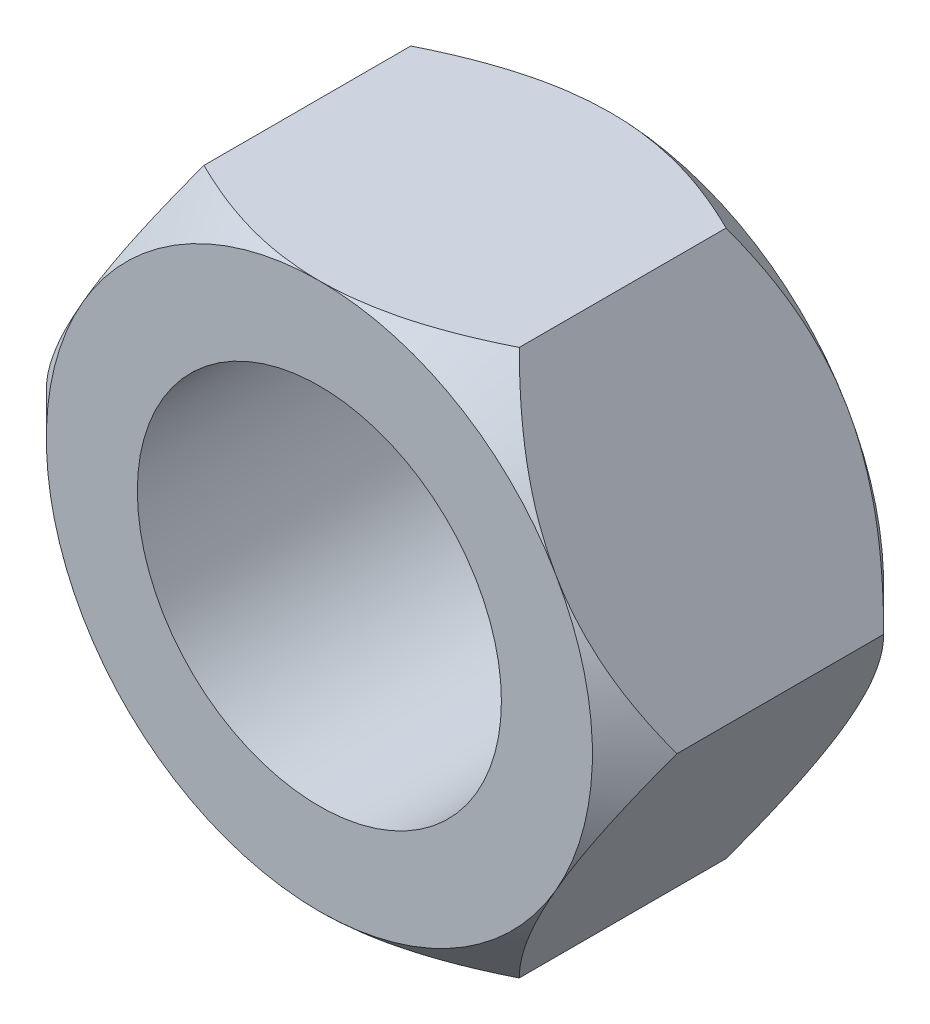
from build123d import *

# Parameters (mm, degrees)
BOSS_EXTRUDE1_DEPTH = 8
SKETCH2_OUTSIDE_W   = 80.35
SKETCH2_OUTSIDE_H   = 75.708
SKETCH2_OUTSIDE_R   = 15
CUT_EXTRUDE1_DEPTH  = 17
CUT_EXTRUDE1_TAPER  = 45
SKETCH3_R           = 10
CUT_EXTRUDE2_DEPTH  = 17


with BuildPart() as part:
    # Sketch1 → Boss-Extrude1 (new body, symmetric)
    with BuildSketch(Plane.XY):
        Polygon((-8.660254038, 15), (-17.320508076, 0), (-8.660254038, -15), (8.660254038, -15), (17.320508076, 0), (8.660254038, 15), align=None)
    extrude(amount=BOSS_EXTRUDE1_DEPTH, both=True)

    # Sketch2 outside → Cut-Extrude1 (cut, through all)
    with BuildSketch(Plane.XY.offset(8)):
        Rectangle(SKETCH2_OUTSIDE_W, SKETCH2_OUTSIDE_H)
        Circle(SKETCH2_OUTSIDE_R, mode=Mode.SUBTRACT)
    cut_extrude1 = extrude(amount=-CUT_EXTRUDE1_DEPTH, taper=CUT_EXTRUDE1_TAPER, mode=Mode.SUBTRACT)

    # Mirror1: Cut-Extrude1 across plane
    add(cut_extrude1.mirror(Plane.XY), mode=Mode.SUBTRACT)

    # Sketch3 → Cut-Extrude2 (cut, through all)
    with BuildSketch(Plane(origin=(0, 0, -8), x_dir=(-1, 0, 0), z_dir=(0, 0, -1))):
        Circle(SKETCH3_R)
    extrude(amount=-CUT_EXTRUDE2_DEPTH, mode=Mode.SUBTRACT)


solid = part.part
